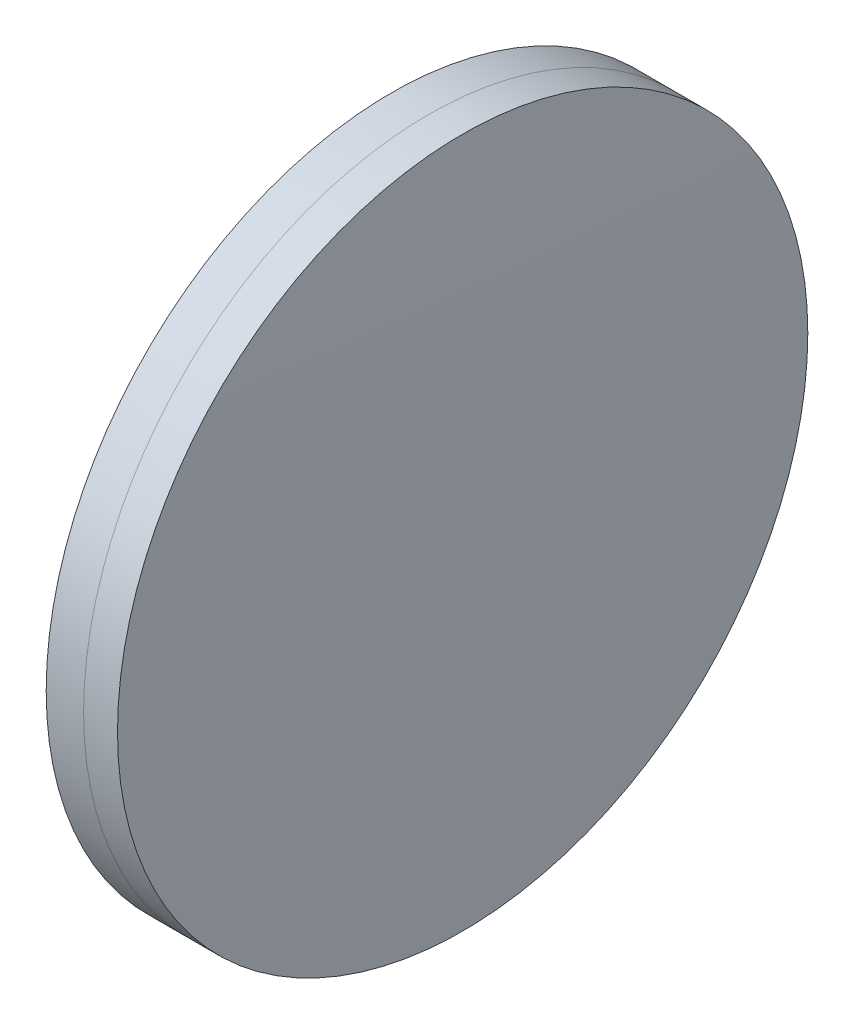
from build123d import *


with BuildPart() as part:
    # 草图1 one side → 旋转1 (revolve)
    with BuildSketch(Plane(origin=(0, 0, 0), x_dir=(1, 0, 0), z_dir=(0, 1, 0)), mode=Mode.PRIVATE) as revolve_1_sk:
        with BuildLine():
            ThreePointArc((610.658509495, 25.4), (610.330817383, 12.701878906), (610.221575906, 0))
            Line((610.221575906, 0), (614.221575906, 0))
            ThreePointArc((614.221575906, 0), (614.018742922, 12.706473982), (613.410450656, 25.4))
            Line((613.410450656, 25.4), (610.658509495, 25.4))
        make_face()
    revolve(revolve_1_sk.sketch.rotate(Axis((124.523309526, 0, 0), (1, 0, 0)), 180), axis=Axis((124.523309526, 0, 0), (1, 0, 0)))  # turned: the seam where the file's is


with BuildPart() as body_2:
    # 草图2 one side → 旋转3 (revolve)
    with BuildSketch(Plane(origin=(0, 0, 0), x_dir=(1, 0, 0), z_dir=(0, 1, 0)), mode=Mode.PRIVATE) as revolve_3_sk:
        with BuildLine():
            Line((615.906292312, 25.4), (613.410450656, 25.4))
            ThreePointArc((613.410450656, 25.4), (614.018742922, 12.706473982), (614.221575906, 0))
            Line((614.221575906, 0), (616.221575906, 0))
            ThreePointArc((616.221575906, 0), (616.142751972, 12.700978346), (615.906292312, 25.4))
        make_face()
    revolve(revolve_3_sk.sketch.rotate(Axis((-0.551919993, 0, 0), (1, 0, 0)), 180), axis=Axis((-0.551919993, 0, 0), (1, 0, 0)))  # turned: the seam where the file's is


solid = Compound([part.part, body_2.part])
